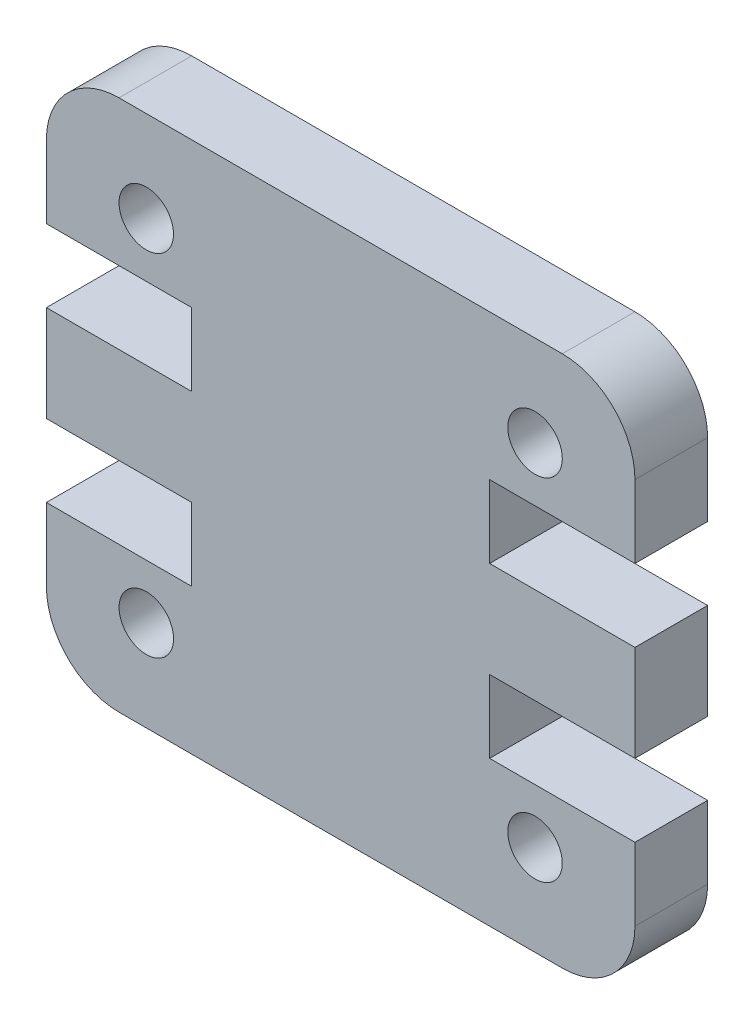
from build123d import *

# Parameters (mm, degrees)
SKETCH1_R           = 0.75
BOSS_EXTRUDE1_DEPTH = 2


with BuildPart() as part:
    # Sketch1 → Boss-Extrude1 (new body)
    with BuildSketch(Plane.XY):
        with BuildLine():
            Line((16.2, 4), (16.2, 2))
            ThreePointArc((16.2, 2), (15.614213562, 0.585786438), (14.2, 0))
            Line((14.2, 0), (2, 0))
            ThreePointArc((2, 0), (0.585786438, 0.585786438), (0, 2))
            Line((0, 2), (0, 4))
            Line((0, 4), (4, 4))
            Line((4, 4), (4, 6))
            Line((4, 6), (0, 6))
            Line((0, 6), (0, 8.645))
            Line((0, 8.645), (4, 8.645))
            Line((4, 8.645), (4, 10.645))
            Line((4, 10.645), (0, 10.645))
            Line((0, 10.645), (0, 12.645))
            ThreePointArc((0, 12.645), (0.585786438, 14.059213562), (2, 14.645))
            Line((2, 14.645), (14.2, 14.645))
            ThreePointArc((14.2, 14.645), (15.614213562, 14.059213562), (16.2, 12.645))
            Line((16.2, 12.645), (16.2, 10.645))
            Line((16.2, 10.645), (12.2, 10.645))
            Line((12.2, 10.645), (12.2, 8.645))
            Line((12.2, 8.645), (16.2, 8.645))
            Line((16.2, 8.645), (16.2, 6))
            Line((16.2, 6), (12.2, 6))
            Line((12.2, 6), (12.2, 4))
            Line((12.2, 4), (16.2, 4))
        make_face()
        with Locations((13.45, 2.5)):
            Circle(SKETCH1_R, mode=Mode.SUBTRACT)
        with Locations((2.75, 12.145)):
            Circle(SKETCH1_R, mode=Mode.SUBTRACT)
        with Locations((13.45, 12.145)):
            Circle(SKETCH1_R, mode=Mode.SUBTRACT)
        with Locations((2.75, 2.5)):
            Circle(SKETCH1_R, mode=Mode.SUBTRACT)
    extrude(amount=BOSS_EXTRUDE1_DEPTH)


solid = part.part
